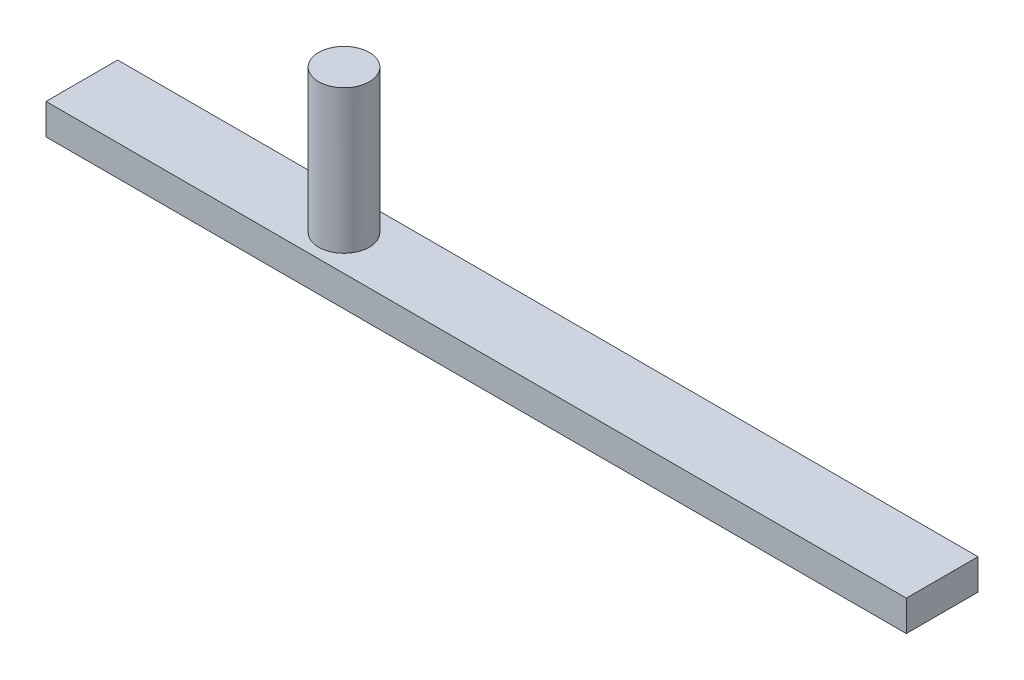
from build123d import *

# Parameters (mm, degrees)
SKETCH1_W           = 1066.8
SKETCH1_H           = 88.9
BOSS_EXTRUDE1_DEPTH = 38.1
SKETCH2_R           = 31.428028039
BOSS_EXTRUDE2_DEPTH = 177.8


with BuildPart() as part:
    # Sketch1 → Boss-Extrude1 (new body)
    with BuildSketch(Plane(origin=(0, 0, 0), x_dir=(1, 0, 0), z_dir=(0, 1, 0))):
        with Locations((533.4, 44.45)):
            Rectangle(SKETCH1_W, SKETCH1_H)
    extrude(amount=BOSS_EXTRUDE1_DEPTH)

    # Sketch2 → Boss-Extrude2 (add)
    with BuildSketch(Plane(origin=(0, 38.1, 0), x_dir=(1, 0, 0), z_dir=(0, 1, 0))):
        with Locations((325.671457389, 43.854789276)):
            Circle(SKETCH2_R)
    extrude(amount=BOSS_EXTRUDE2_DEPTH)


solid = part.part
